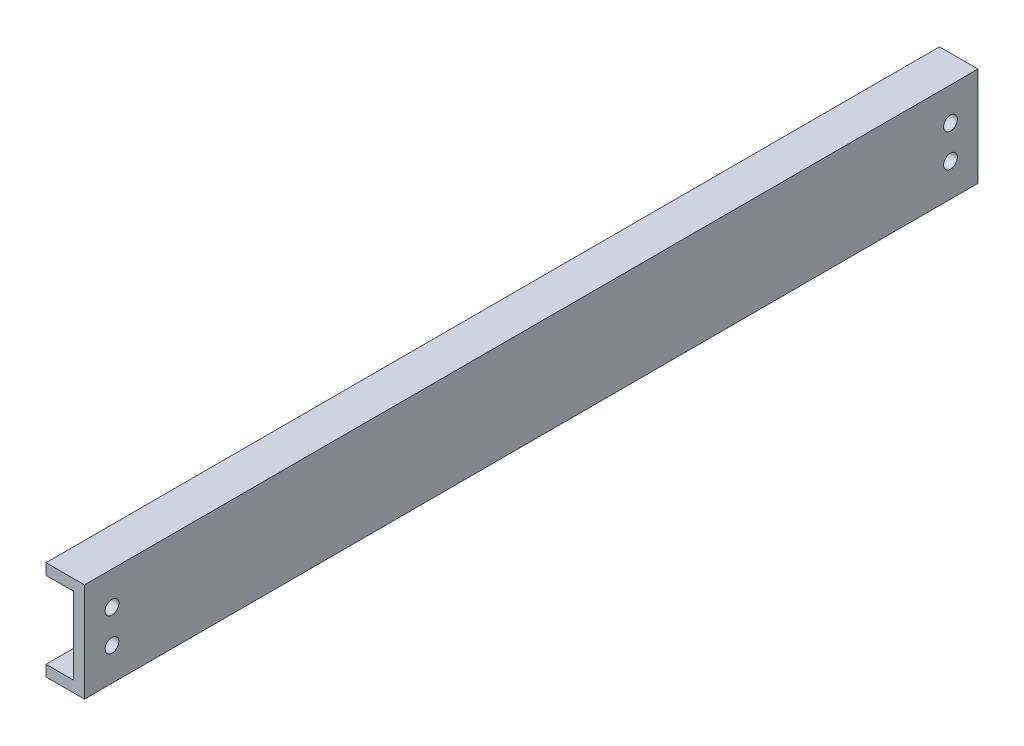
from build123d import *

# Parameters (mm, degrees)
BOSS_EXTRUDE1_DEPTH = 162.5
SKETCH2_R           = 1.25
CUT_EXTRUDE1_DEPTH  = 8


with BuildPart() as part:
    # Sketch1 → Boss-Extrude1 (new body)
    with BuildSketch(Plane.XY):
        Polygon((-7, 9.888282785), (0, 9.888282785), (0, -8.111717215), (-7, -8.111717215), (-7, -6.111717215), (-2, -6.111717215), (-2, 7.888282785), (-7, 7.888282785), align=None)
    extrude(amount=-BOSS_EXTRUDE1_DEPTH)

    # Sketch2 → Cut-Extrude1 (cut, through all)
    with BuildSketch(Plane(origin=(0, 0, 0), x_dir=(0, 0, -1), z_dir=(1, 0, 0))):
        with Locations((5, 3.888282785)):
            Circle(SKETCH2_R)
        with Locations((5, -2.111717215)):
            Circle(SKETCH2_R)
        with Locations((157.5, -2.111717215)):
            Circle(SKETCH2_R)
        with Locations((157.5, 3.888282785)):
            Circle(SKETCH2_R)
    extrude(amount=-CUT_EXTRUDE1_DEPTH, mode=Mode.SUBTRACT)


solid = part.part
